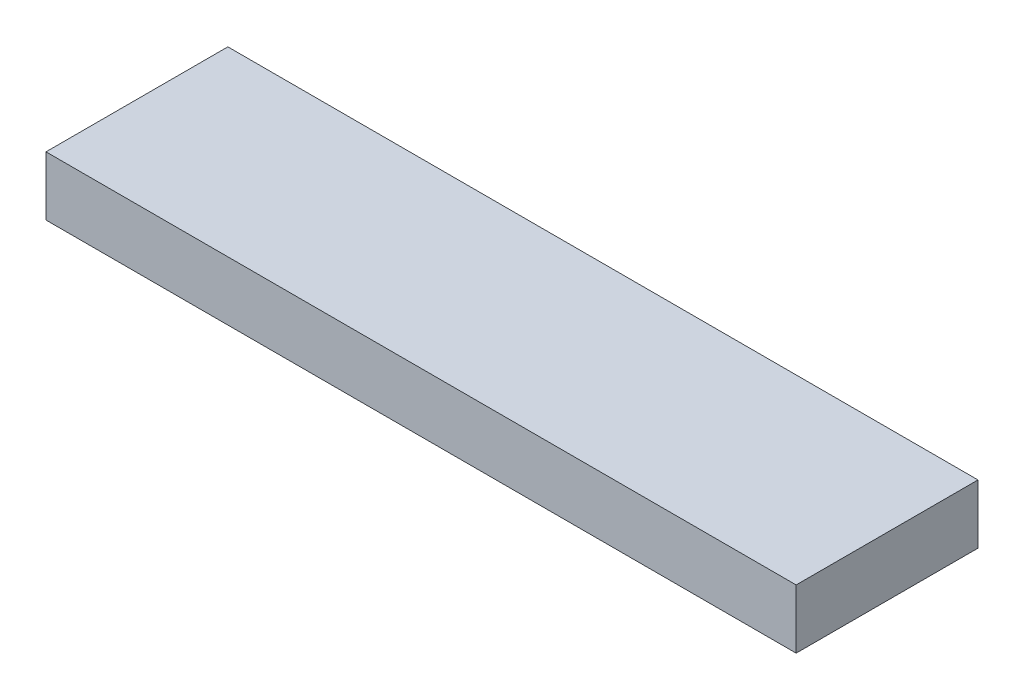
from build123d import *

# Parameters (mm, degrees)
SKETCH1_W           = 41.91
SKETCH1_H           = 10.16
BOSS_EXTRUDE1_DEPTH = 3.302
SKETCH2_R           = 1.174037675
BOSS_EXTRUDE2_DEPTH = 0.635


with BuildPart() as part:
    # Sketch1 → Boss-Extrude1 (new body)
    with BuildSketch(Plane(origin=(0, 0, 0), x_dir=(1, 0, 0), z_dir=(0, 1, 0))):
        Rectangle(SKETCH1_W, SKETCH1_H)
    extrude(amount=BOSS_EXTRUDE1_DEPTH)

    # Sketch2 → Boss-Extrude2 (add)
    with BuildSketch(Plane.XZ):
        with Locations((-13.462, 0)):
            Circle(SKETCH2_R)
        with Locations((-8.128, 0)):
            Circle(SKETCH2_R)
        with Locations((8.128, 0)):
            Circle(SKETCH2_R)
        with Locations((13.462, 0)):
            Circle(SKETCH2_R)
    extrude(amount=BOSS_EXTRUDE2_DEPTH)


solid = part.part
